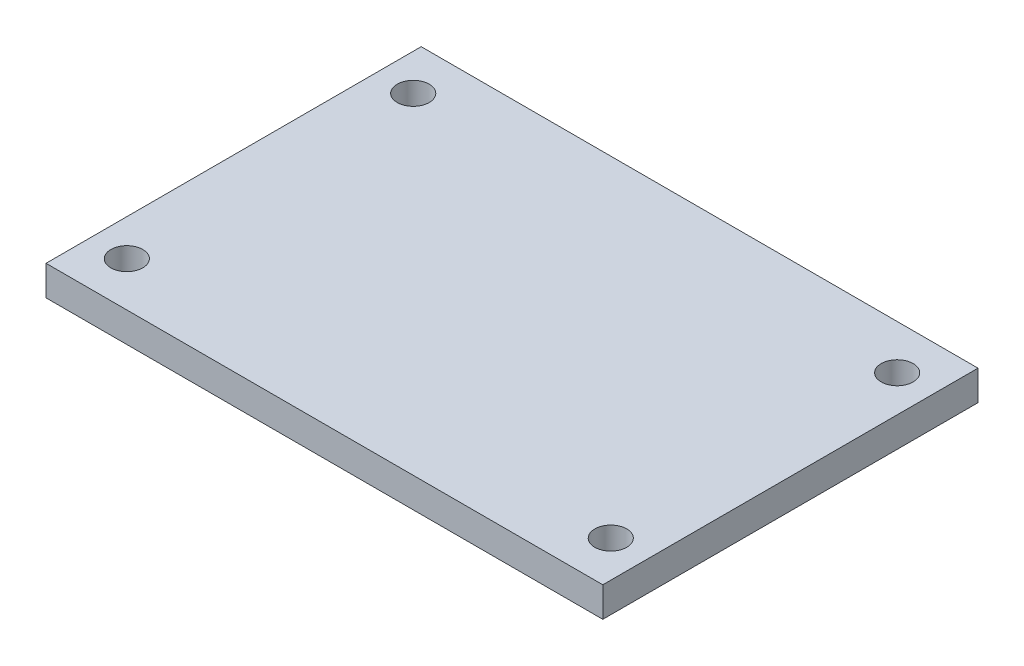
from build123d import *

# Parameters (mm, degrees)
SKETCH1_W                = 55.8
SKETCH1_H                = 37.6
BOSS_EXTRUDE1_DEPTH      = 3
M3_CLEARANCE_HOLE1_D     = 3.2
M3_CLEARANCE_HOLE1_DEPTH = 3


with BuildPart() as part:
    # Sketch1 → Boss-Extrude1 (new body)
    with BuildSketch(Plane(origin=(0, 0, 0), x_dir=(1, 0, 0), z_dir=(0, 1, 0))):
        with Locations((27.9, 18.8)):
            Rectangle(SKETCH1_W, SKETCH1_H)
    extrude(amount=BOSS_EXTRUDE1_DEPTH)

    # M3 Clearance Hole1
    with Locations(Plane(origin=(0, 3, 0), x_dir=(1, 0, 0), z_dir=(0, 1, 0))):
        with Locations((3.65, 33.15), (52.15, 33.15), (52.15, 4.45), (3.65, 4.45)):
            Hole(M3_CLEARANCE_HOLE1_D / 2, depth=M3_CLEARANCE_HOLE1_DEPTH)


solid = part.part
